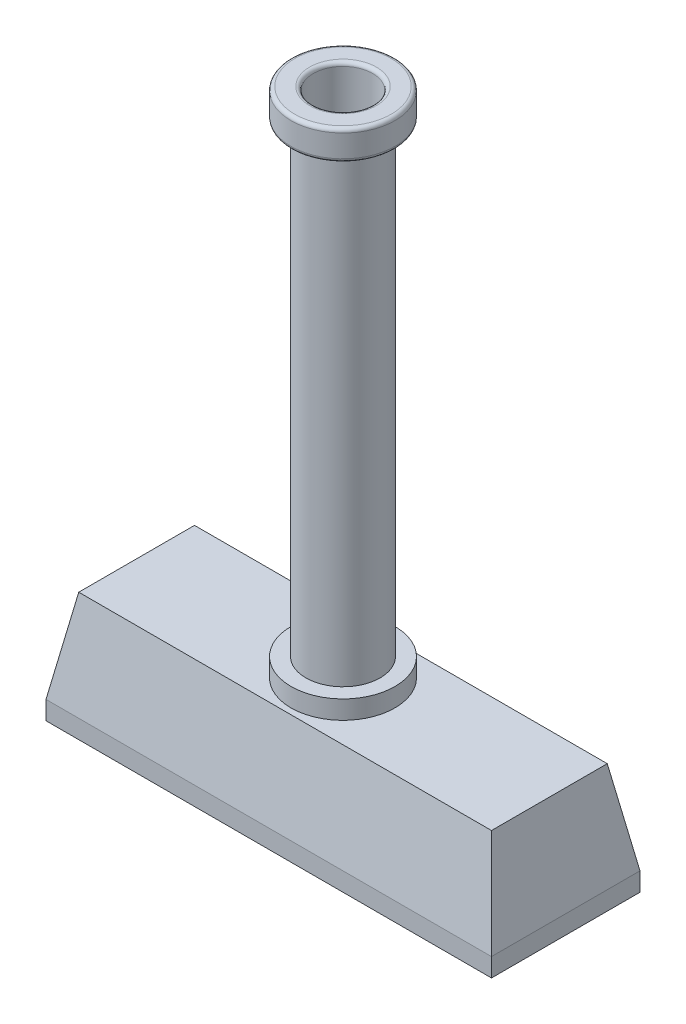
from build123d import *

# Parameters (mm, degrees)
SKETCH1_W           = 120
SKETCH1_H           = 40
BOSS_EXTRUDE1_DEPTH = 25
BOSS_EXTRUDE1_TAPER = 10
SKETCH2_R           = 14
BOSS_EXTRUDE2_DEPTH = 5
SKETCH3_R           = 10
BOSS_EXTRUDE3_DEPTH = 125
SKETCH4_R           = 14
BOSS_EXTRUDE4_DEPTH = 8
SKETCH5_R           = 8
CUT_EXTRUDE1_DEPTH  = 150
FILLET1_R           = 1
SKETCH6_W           = 120
SKETCH6_H           = 40
BOSS_EXTRUDE5_DEPTH = 5


with BuildPart() as part:
    # Sketch1 → Boss-Extrude1 (new body)
    with BuildSketch(Plane(origin=(0, 0, 0), x_dir=(1, 0, 0), z_dir=(0, 1, 0))):
        Rectangle(SKETCH1_W, SKETCH1_H)
    extrude(amount=BOSS_EXTRUDE1_DEPTH, taper=BOSS_EXTRUDE1_TAPER)

    # Sketch2 → Boss-Extrude2 (add)
    with BuildSketch(Plane(origin=(0, 25, 0), x_dir=(1, 0, 0), z_dir=(0, 1, 0))):
        Circle(SKETCH2_R)
    extrude(amount=BOSS_EXTRUDE2_DEPTH)

    # Sketch3 → Boss-Extrude3 (add)
    with BuildSketch(Plane(origin=(0, 30, 0), x_dir=(1, 0, 0), z_dir=(0, 1, 0))):
        Circle(SKETCH3_R)
    extrude(amount=BOSS_EXTRUDE3_DEPTH)

    # Sketch4 → Boss-Extrude4 (add)
    with BuildSketch(Plane(origin=(0, 155, 0), x_dir=(1, 0, 0), z_dir=(0, 1, 0))):
        Circle(SKETCH4_R)
    extrude(amount=BOSS_EXTRUDE4_DEPTH)

    # Sketch5 → Cut-Extrude1 (cut)
    with BuildSketch(Plane(origin=(0, 163, 0), x_dir=(1, 0, 0), z_dir=(0, 1, 0))):
        Circle(SKETCH5_R)
    extrude(amount=-CUT_EXTRUDE1_DEPTH, mode=Mode.SUBTRACT)

    # Fillet1
    fillet1_edges = [part.edges().sort_by_distance(p)[0] for p in [
        (-10, 155, 0),
        (-14, 155, 0),
        (-14, 163, 0),
        (-8, 163, 0),
    ]]
    fillet(fillet1_edges, radius=FILLET1_R)

    # Sketch6 → Boss-Extrude5 (add)
    with BuildSketch(Plane.XZ):
        Rectangle(SKETCH6_W, SKETCH6_H)
    extrude(amount=BOSS_EXTRUDE5_DEPTH)


solid = part.part
